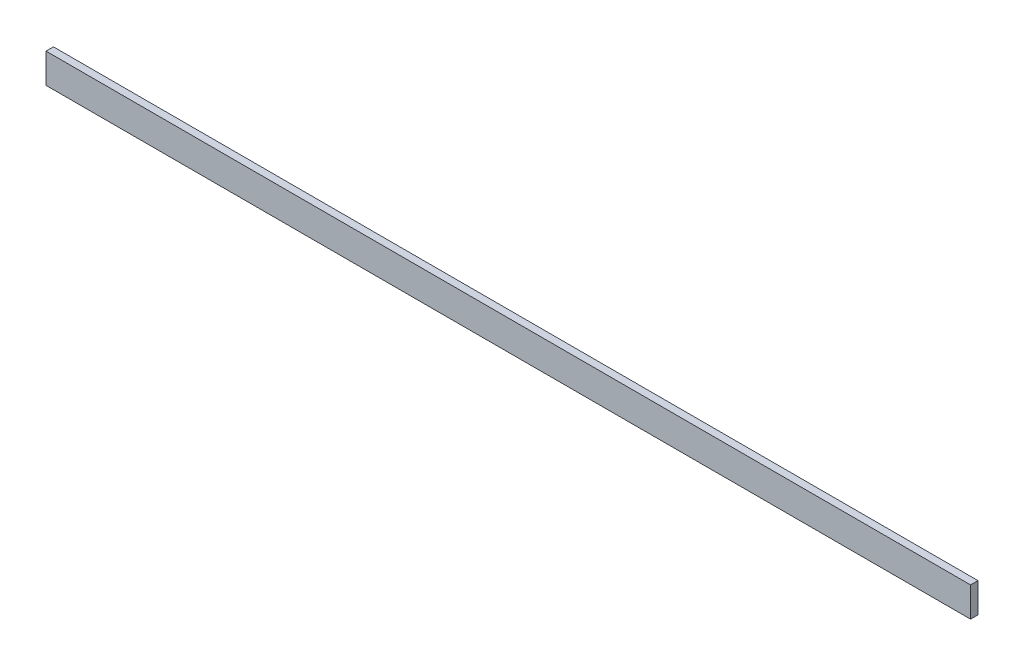
from build123d import *

# Parameters (mm, degrees)
SKETCH1_W           = 395.475
SKETCH1_H           = 12.7
BOSS_EXTRUDE1_DEPTH = 3.175


with BuildPart() as part:
    # Sketch1 → Boss-Extrude1 (new body)
    with BuildSketch(Plane.XY):
        with Locations((-158.05, 297.349000032)):
            Rectangle(SKETCH1_W, SKETCH1_H)
    extrude(amount=BOSS_EXTRUDE1_DEPTH)


solid = part.part
